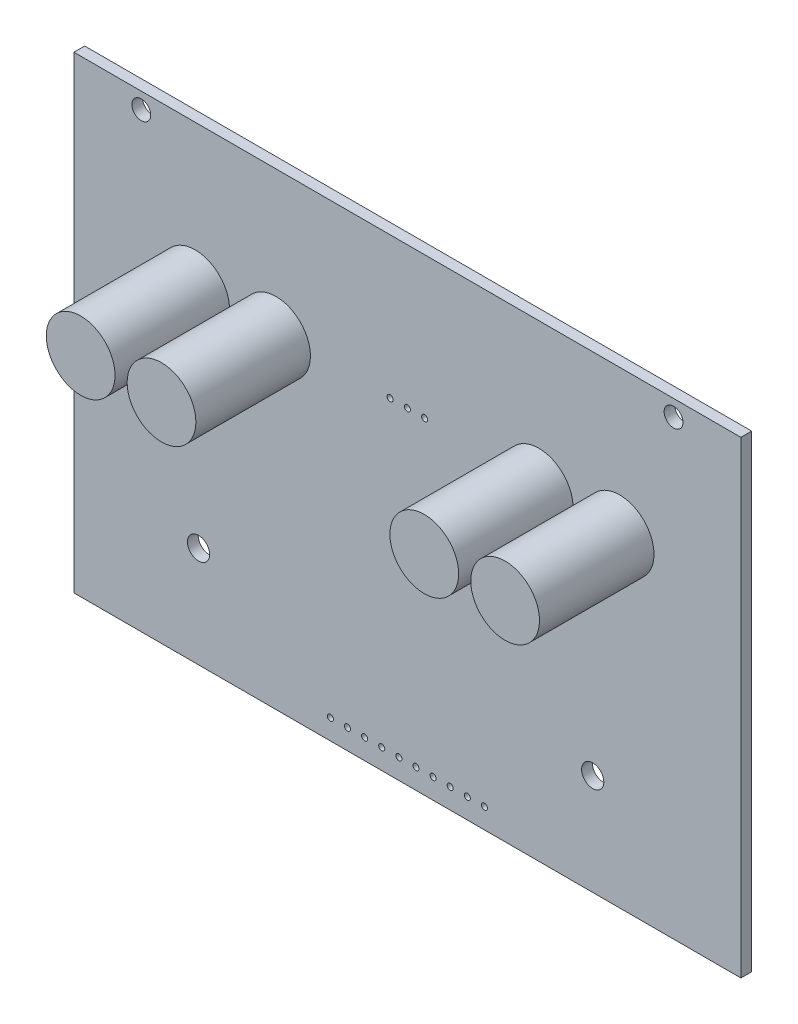
from build123d import *

# Parameters (mm, degrees)
SKETCH1_W               = 99
SKETCH1_H               = 69.5
BOSS_EXTRUDE1_DEPTH     = 1.6
SKETCH2_R               = 5.1
BOSS_EXTRUDE2_DEPTH     = 17
SKETCH3_R               = 1.4
SKETCH3_R_2             = 1.65
SKETCH3_R_3             = 0.45
CUT_EXTRUDE1_DEPTH      = 18
CUT_EXTRUDE1_DEPTH_BACK = 2.6


with BuildPart() as part:
    # Sketch1 → Boss-Extrude1 (new body)
    with BuildSketch(Plane.XY):
        with Locations((49.5, 34.75)):
            Rectangle(SKETCH1_W, SKETCH1_H)
    extrude(amount=BOSS_EXTRUDE1_DEPTH)

    # Sketch2 → Boss-Extrude2 (add)
    with BuildSketch(Plane.XY.offset(1.6)):
        with Locations((18, 48)):
            Circle(SKETCH2_R)
        with Locations((30, 48)):
            Circle(SKETCH2_R)
        with Locations((69, 48)):
            Circle(SKETCH2_R)
        with Locations((81, 48)):
            Circle(SKETCH2_R)
    extrude(amount=BOSS_EXTRUDE2_DEPTH)

    # Sketch3 → Cut-Extrude1 (cut, two sides)
    with BuildSketch(Plane.XY.offset(1.6)) as cut_extrude1_sk:
        with Locations((10, 67.1)):
            Circle(SKETCH3_R)
        with Locations((89, 67.1)):
            Circle(SKETCH3_R)
        with Locations((18.5, 15)):
            Circle(SKETCH3_R_2)
        with Locations((77, 15)):
            Circle(SKETCH3_R_2)
        with Locations((49.5, 48.5)):
            Circle(SKETCH3_R_3)
        with Locations((52.06, 48.5)):
            Circle(SKETCH3_R_3)
        with Locations((46.94, 48.5)):
            Circle(SKETCH3_R_3)
        with Locations((43.15, 3)):
            Circle(SKETCH3_R_3)
        with Locations((45.69, 3)):
            Circle(SKETCH3_R_3)
        with Locations((48.23, 3)):
            Circle(SKETCH3_R_3)
        with Locations((50.77, 3)):
            Circle(SKETCH3_R_3)
        with Locations((53.31, 3)):
            Circle(SKETCH3_R_3)
        with Locations((55.85, 3)):
            Circle(SKETCH3_R_3)
        with Locations((58.39, 3)):
            Circle(SKETCH3_R_3)
        with Locations((60.93, 3)):
            Circle(SKETCH3_R_3)
        with Locations((40.61, 3)):
            Circle(SKETCH3_R_3)
        with Locations((38.07, 3)):
            Circle(SKETCH3_R_3)
    extrude(amount=CUT_EXTRUDE1_DEPTH, mode=Mode.SUBTRACT)
    extrude(cut_extrude1_sk.sketch, amount=-CUT_EXTRUDE1_DEPTH_BACK, mode=Mode.SUBTRACT)


solid = part.part
